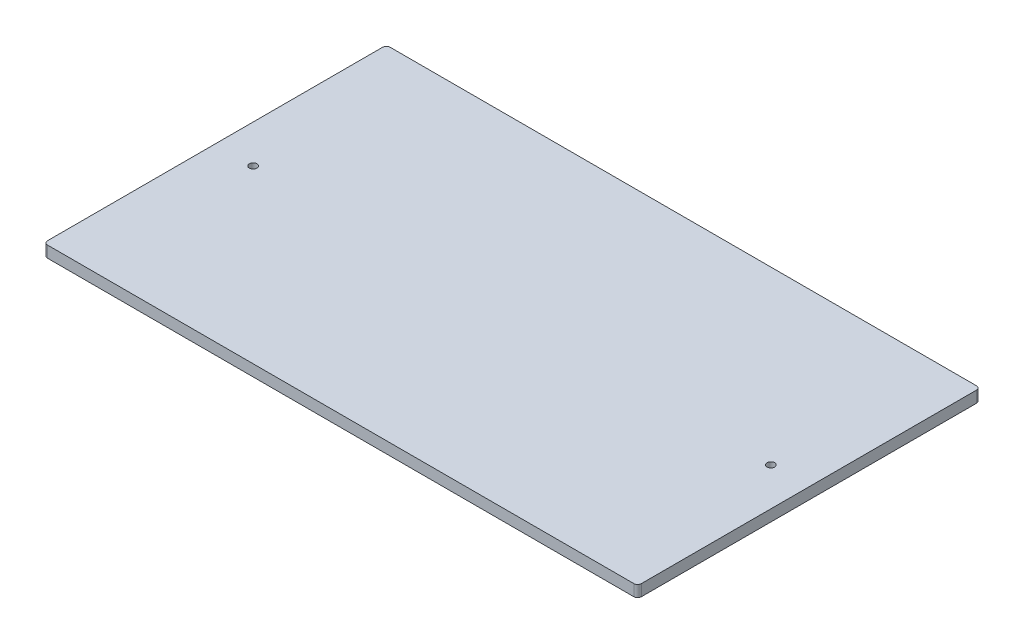
from build123d import *

# Parameters (mm, degrees)
SKETCH1_W           = 156
SKETCH1_H           = 90
BOSS_EXTRUDE1_DEPTH = 3
FILLET1_R           = 1
SKETCH2_R           = 1
CUT_EXTRUDE1_DEPTH  = 4


with BuildPart() as part:
    # Sketch1 → Boss-Extrude1 (new body)
    with BuildSketch(Plane(origin=(0, 0, 0), x_dir=(1, 0, 0), z_dir=(0, 1, 0))):
        with Locations((78, 45)):
            Rectangle(SKETCH1_W, SKETCH1_H)
    extrude(amount=BOSS_EXTRUDE1_DEPTH)

    # Fillet1
    fillet1_edges = [part.edges().sort_by_distance(p)[0] for p in [
        (0, 1.5, -90),
        (156, 1.5, -90),
        (156, 1.5, 0),
        (0, 1.5, 0),
    ]]
    fillet(fillet1_edges, radius=FILLET1_R)

    # Sketch2 → Cut-Extrude1 (cut, through all)
    with BuildSketch(Plane(origin=(0, 3, 0), x_dir=(1, 0, 0), z_dir=(0, 1, 0))):
        with Locations((146, 45)):
            Circle(SKETCH2_R)
        with Locations((10, 45)):
            Circle(SKETCH2_R)
    extrude(amount=-CUT_EXTRUDE1_DEPTH, mode=Mode.SUBTRACT)


solid = part.part
